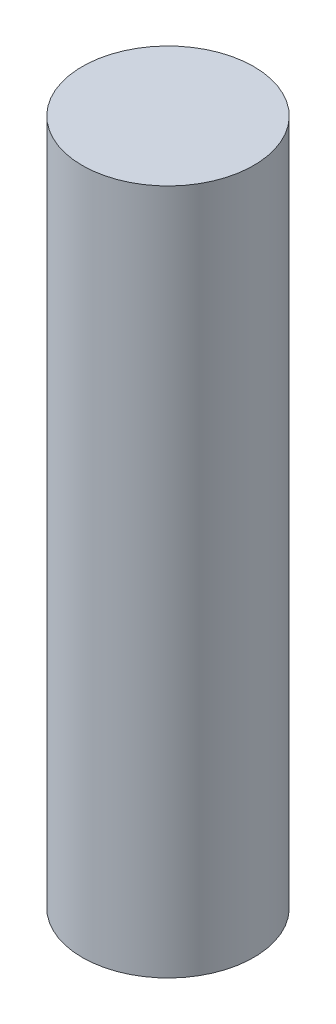
from build123d import *

# Parameters (mm, degrees)
SKETCH1_R           = 3.175
BOSS_EXTRUDE1_DEPTH = 12.7


with BuildPart() as part:
    # Sketch1 → Boss-Extrude1 (new body, symmetric)
    with BuildSketch(Plane(origin=(0, 0, 0), x_dir=(1, 0, 0), z_dir=(0, 1, 0))):
        Circle(SKETCH1_R)
    extrude(amount=BOSS_EXTRUDE1_DEPTH, both=True)


solid = part.part
